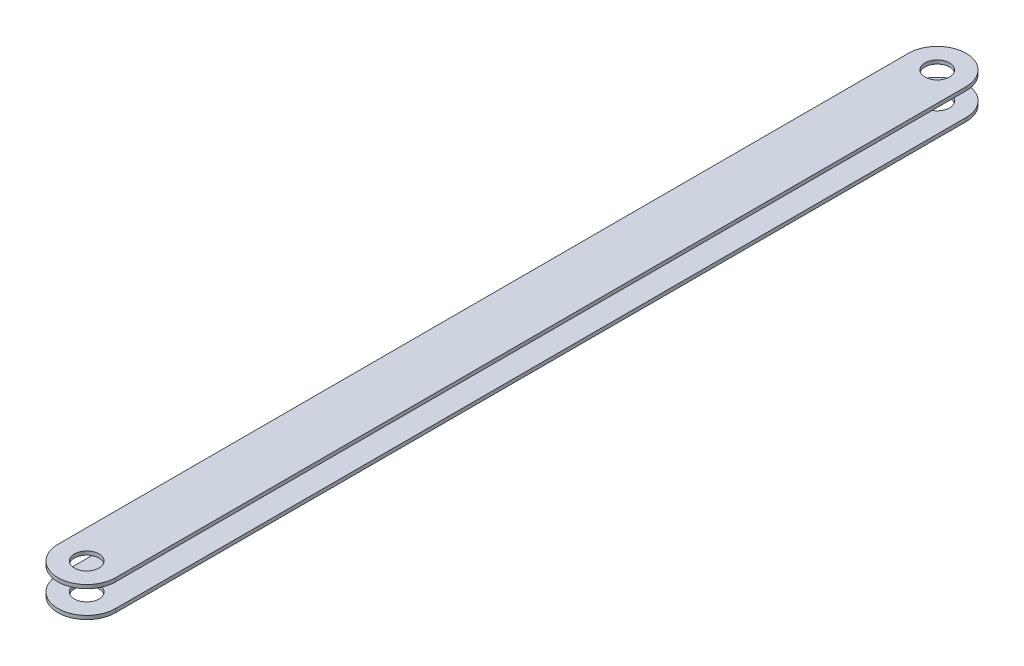
from build123d import *

# Parameters (mm, degrees)
SKETCH1_W           = 1.2
SKETCH1_H           = 7.6
SKETCH1_W_2         = 19
SKETCH1_H_2         = 1.2
BOSS_EXTRUDE1_DEPTH = 299
SKETCH3_R           = 4.05
CUT_EXTRUDE2_DEPTH  = 370
CUT_EXTRUDE4_DEPTH  = 370


with BuildPart() as part:
    # Sketch1 → Boss-Extrude1 (new body)
    with BuildSketch(Plane.XY):
        Rectangle(SKETCH1_W, SKETCH1_H)
        with Locations((0, -4.4)):
            Rectangle(SKETCH1_W_2, SKETCH1_H_2)
        with Locations((0, 4.4)):
            Rectangle(SKETCH1_W_2, SKETCH1_H_2)
    extrude(amount=BOSS_EXTRUDE1_DEPTH)

    # Sketch3 → Cut-Extrude2 (cut)
    with BuildSketch(Plane(origin=(0, 5, 0), x_dir=(1, 0, 0), z_dir=(0, 1, 0))):
        with BuildLine():
            Line((-9.5, 0), (-9.5, -9.5))
            ThreePointArc((-9.5, -9.5), (-6.717514436, -2.782485594), (-4.2e-08, 0))
            Line((-4.2e-08, 0), (-9.5, 0))
        make_face()
        with BuildLine():
            Line((9.5, 0), (-4.2e-08, 0))
            ThreePointArc((-4.2e-08, 0), (6.717514406, -2.782485564), (9.5, -9.5))
            Line((9.5, -9.5), (9.5, 0))
        make_face()
        with BuildLine():
            ThreePointArc((14.5, -9.5), (0, 5), (-14.5, -9.5))
            Line((-14.5, -9.5), (-9.5, -9.5))
            Line((-9.5, -9.5), (-9.5, 0))
            Line((-9.5, 0), (-4.2e-08, 0))
            Line((-4.2e-08, 0), (9.5, 0))
            Line((9.5, 0), (9.5, -9.5))
            Line((9.5, -9.5), (14.5, -9.5))
        make_face()
        with Locations((0, -9.5)):
            Circle(SKETCH3_R)
    cut_extrude2 = extrude(amount=-CUT_EXTRUDE2_DEPTH, mode=Mode.SUBTRACT)

    # Mirror1: Cut-Extrude2 across plane
    add(cut_extrude2.mirror(Plane.XY.offset(149.5)), mode=Mode.SUBTRACT)

    # Sketch6 → Cut-Extrude4 (cut)
    with BuildSketch(Plane.ZY.offset(0.6)):
        with BuildLine():
            Line((20, -3.8), (-1, -3.8))
            Line((-1, -3.8), (-1, 3.8))
            Line((-1, 3.8), (20, 3.8))
            Line((20, 3.8), (20, 3.464101615))
            ThreePointArc((20, 3.464101615), (20.122035527, 3.13677478), (20.428571429, 2.969229956))
            ThreePointArc((20.428571429, 2.969229956), (23, 0), (20.428571429, -2.969229956))
            ThreePointArc((20.428571429, -2.969229956), (20.122035527, -3.13677478), (20, -3.464101615))
            Line((20, -3.464101615), (20, -3.8))
        make_face()
    cut_extrude4 = extrude(amount=-CUT_EXTRUDE4_DEPTH, mode=Mode.SUBTRACT)

    # Mirror3: Cut-Extrude4 across plane
    add(cut_extrude4.mirror(Plane.XY.offset(149.5)), mode=Mode.SUBTRACT)


solid = part.part
